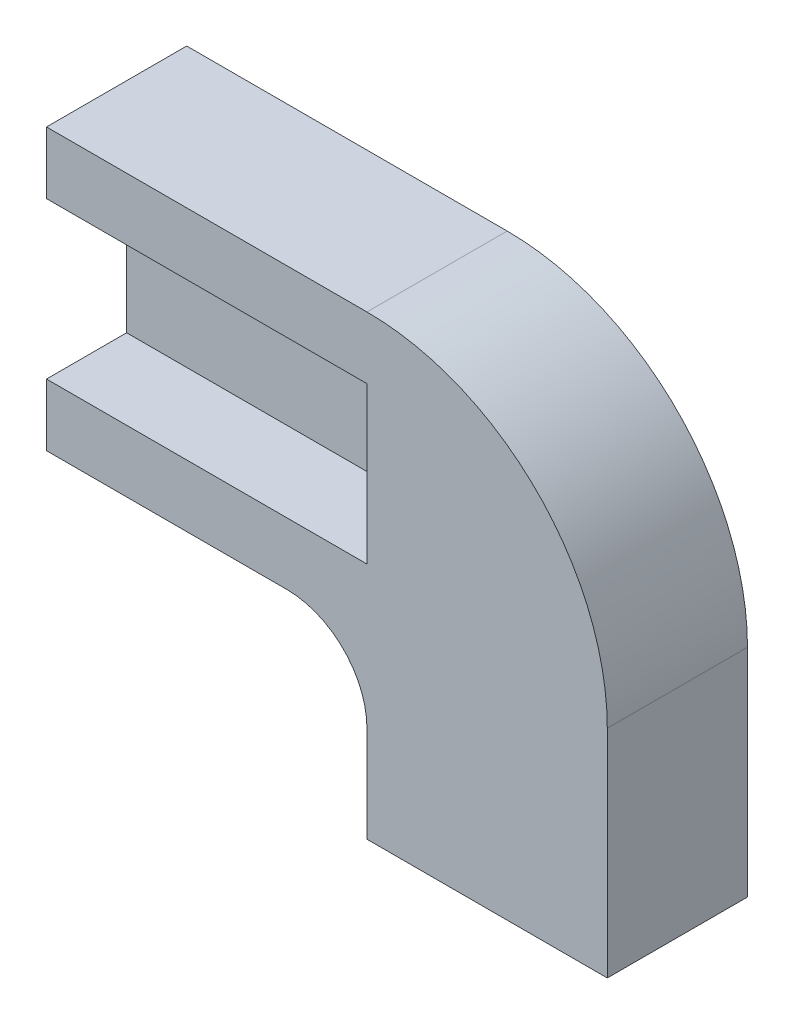
from build123d import *

# Parameters (mm, degrees)
SKETCH1_W           = 17.78
SKETCH1_H           = 14.478
BOSS_EXTRUDE1_DEPTH = 4.445
SKETCH2_W           = 10.16
SKETCH2_H           = 5.588
CUT_EXTRUDE1_DEPTH  = 5.445
SKETCH3_W           = 10.16
SKETCH3_H           = 4.953
CUT_EXTRUDE2_DEPTH  = 2.54
FILLET1_R           = 2.54
FILLET2_R           = 7.62


with BuildPart() as part:
    # Sketch1 → Boss-Extrude1 (new body)
    with BuildSketch(Plane.XY.offset(4.445)):
        with Locations((8.89, -7.239)):
            Rectangle(SKETCH1_W, SKETCH1_H)
    extrude(amount=-BOSS_EXTRUDE1_DEPTH)

    # Sketch2 → Cut-Extrude1 (cut, through all)
    with BuildSketch(Plane(origin=(0, 0, 0), x_dir=(-1, 0, 0), z_dir=(0, 0, -1))):
        with Locations((-5.08, -11.684)):
            Rectangle(SKETCH2_W, SKETCH2_H)
    extrude(amount=-CUT_EXTRUDE1_DEPTH, mode=Mode.SUBTRACT)

    # Sketch3 → Cut-Extrude2 (cut)
    with BuildSketch(Plane.XY.offset(4.445)):
        with Locations((5.08, -4.445)):
            Rectangle(SKETCH3_W, SKETCH3_H)
    extrude(amount=-CUT_EXTRUDE2_DEPTH, mode=Mode.SUBTRACT)

    # Fillet1
    fillet1_edges = [part.edges().sort_by_distance(p)[0] for p in [
        (10.16, -8.89, 2.2225),
    ]]
    fillet(fillet1_edges, radius=FILLET1_R)

    # Fillet2
    fillet2_edges = [part.edges().sort_by_distance(p)[0] for p in [
        (17.78, 0, 2.2225),
    ]]
    fillet(fillet2_edges, radius=FILLET2_R)


solid = part.part
